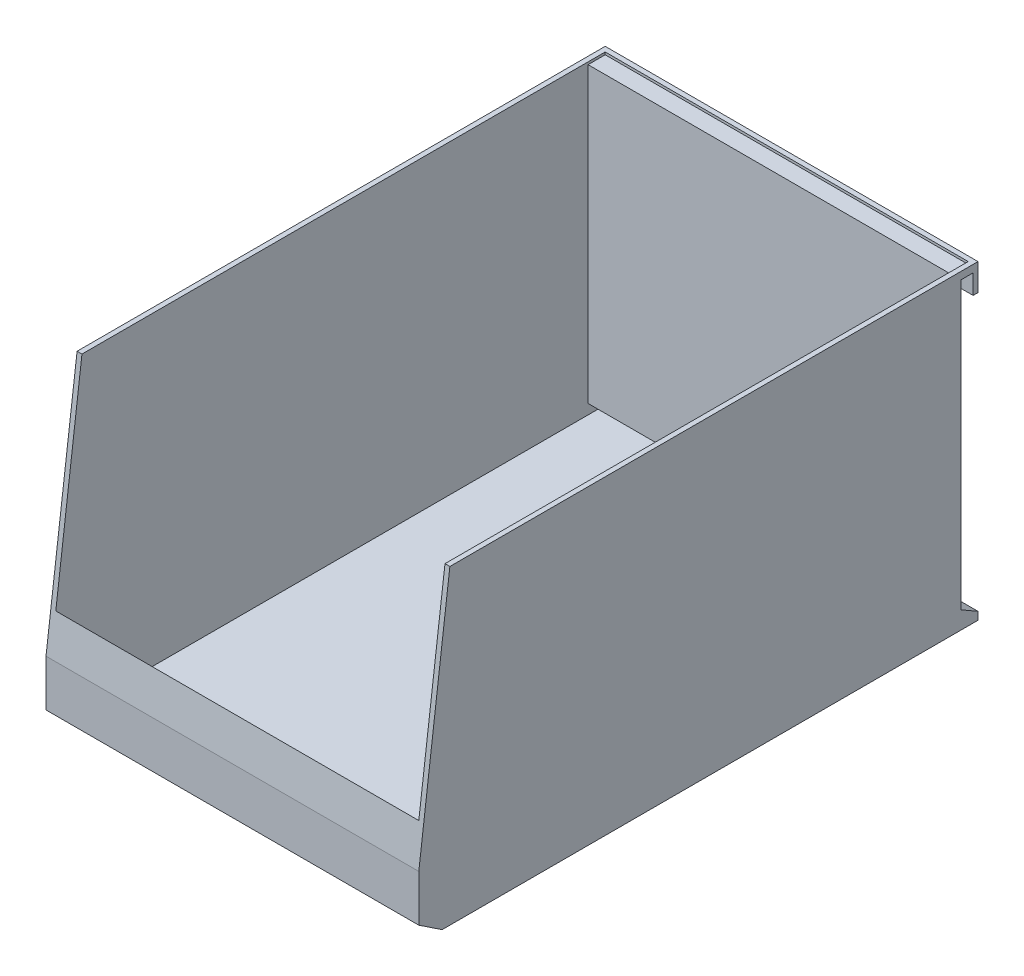
from build123d import *

# Parameters (mm, degrees)
SKETCH1_W           = 152.4
SKETCH1_H           = 228.6
BOSS_EXTRUDE1_DEPTH = 127
CUT_EXTRUDE1_DEPTH  = 153.4
CUT_EXTRUDE2_DEPTH  = 153.4
SHELL1_T            = -2


with BuildPart() as part:
    # Sketch1 → Boss-Extrude1 (new body)
    with BuildSketch(Plane(origin=(0, 0, 0), x_dir=(1, 0, 0), z_dir=(0, 1, 0))):
        Rectangle(SKETCH1_W, SKETCH1_H)
    extrude(amount=BOSS_EXTRUDE1_DEPTH)

    # Sketch2 → Cut-Extrude1 (cut, through all)
    with BuildSketch(Plane(origin=(76.2, 0, 0), x_dir=(0, 0, -1), z_dir=(1, 0, 0))):
        Polygon((-101.6, 127), (-114.3, 25.4), (-114.3, 127), align=None)
        Polygon((-114.3, 6.35), (-114.3, 0), (-104.775, 0), align=None)
    extrude(amount=-CUT_EXTRUDE1_DEPTH, mode=Mode.SUBTRACT)

    # Sketch3 → Cut-Extrude2 (cut, through all)
    with BuildSketch(Plane(origin=(76.2, 0, 0), x_dir=(0, 0, -1), z_dir=(1, 0, 0))):
        Polygon((107.3, 7.216451884), (107.3, 116), (107.3, 124), (112.3, 124), (112.3, 116), (114.3, 116), (114.3, 3.175), align=None)
    extrude(amount=-CUT_EXTRUDE2_DEPTH, mode=Mode.SUBTRACT)

    # Shell1
    shell1_openings = [part.faces().sort_by_distance(p)[0] for p in [
        (0, 127, -6.35),
        (0, 76.2, 107.95),
    ]]
    offset(amount=SHELL1_T, openings=shell1_openings, kind=Kind.INTERSECTION)


solid = part.part
